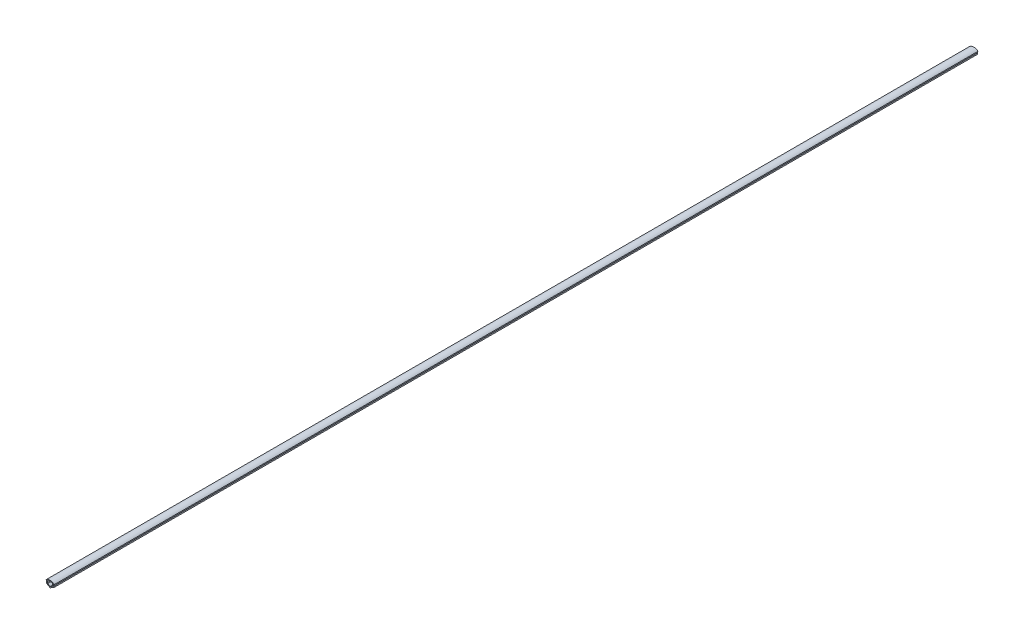
from build123d import *

# Parameters (mm, degrees)
EXTRUDE_1_DEPTH = 1000


with BuildPart() as part:
    # Эскиз1 → Бобышка-Вытянуть1 (new body)
    with BuildSketch(Plane.XY):
        with BuildLine():
            Line((0, 0), (-4.25, 2.453738644))
            Line((-4.25, 2.453738644), (-3.75, 3.319764048))
            Line((-3.75, 3.319764048), (-3.75, 5.332682252))
            Line((-3.75, 5.332682252), (-4.534589287, 5.332682252))
            ThreePointArc((-4.534589287, 5.332682252), (0, 7), (4.534589287, 5.332682252))
            Line((4.534589287, 5.332682252), (3.75, 5.332682252))
            Line((3.75, 5.332682252), (3.75, 3.319764048))
            Line((3.75, 3.319764048), (4.25, 2.453738644))
            Line((4.25, 2.453738644), (0, 0))
        make_face()
        with BuildLine():
            Line((0, 1.154700538), (-2.75, 2.742413779))
            Line((-2.75, 2.742413779), (-2.75, 5.332682252))
            ThreePointArc((-2.75, 5.332682252), (0, 6), (2.75, 5.332682252))
            Line((2.75, 5.332682252), (2.75, 2.742413779))
            Line((2.75, 2.742413779), (0, 1.154700538))
        make_face(mode=Mode.SUBTRACT)
    extrude(amount=EXTRUDE_1_DEPTH)


solid = part.part
